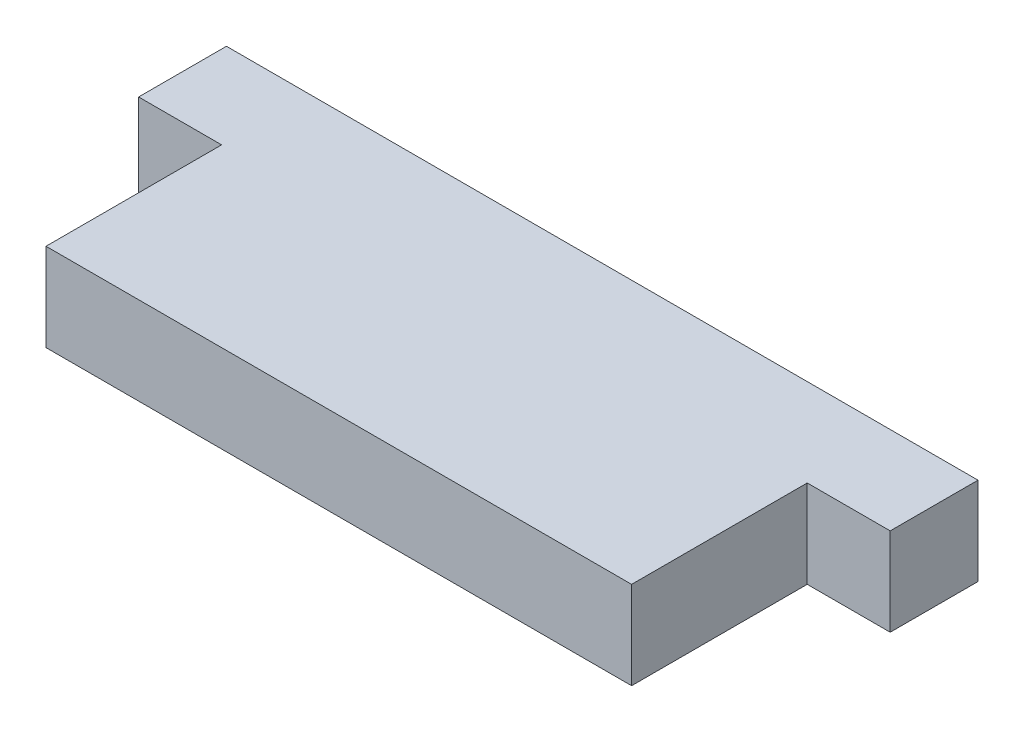
from build123d import *

# Parameters (mm, degrees)
BOSS_EXTRUDE1_DEPTH = 6.35


with BuildPart() as part:
    # Sketch1 → Boss-Extrude1 (new body)
    with BuildSketch(Plane(origin=(0, 0, 0), x_dir=(1, 0, 0), z_dir=(0, 1, 0))):
        Polygon((0, 0), (0, 12.7), (-6.0000896, 12.7), (-6.0000896, 19.05), (48.350089736, 19.05), (48.350089736, 12.7), (42.350000136, 12.7), (42.350000136, 0), align=None)
    extrude(amount=BOSS_EXTRUDE1_DEPTH)


solid = part.part
